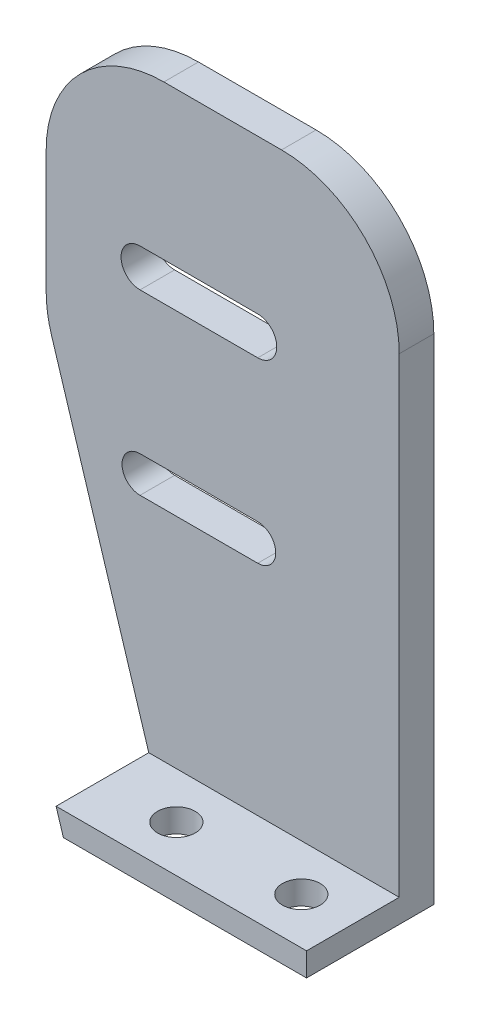
from build123d import *

# Parameters (mm, degrees)
SKETCH1_W                      = 30
SKETCH1_H                      = 10.814576134
BOSS_EXTRUDE1_DEPTH            = 2
SKETCH2_W                      = 30
SKETCH2_H                      = 2.938330184
BOSS_EXTRUDE2_DEPTH            = 50
CUT_EXTRUDE1_DEPTH             = 11.814576135
CUT_EXTRUDE2_REACH             = 4
SKETCH4_R                      = 1.6
CUT_EXTRUDE3_REACH             = 8.878
CUT_EXTRUDE3_DIRECTION_2_REACH = 5.937
FILLET1_R                      = 10


with BuildPart() as part:
    # Sketch1 → Boss-Extrude1 (new body)
    with BuildSketch(Plane(origin=(0, 0, 0), x_dir=(1, 0, 0), z_dir=(0, 1, 0))):
        with Locations((0, -1.470280193)):
            Rectangle(SKETCH1_W, SKETCH1_H)
    extrude(amount=BOSS_EXTRUDE1_DEPTH)

    # Sketch2 → Boss-Extrude2 (add)
    with BuildSketch(Plane(origin=(0, 2, 0), x_dir=(1, 0, 0), z_dir=(0, 1, 0))):
        with Locations((0, 2.467842782)):
            Rectangle(SKETCH2_W, SKETCH2_H)
    extrude(amount=BOSS_EXTRUDE2_DEPTH)

    # Sketch3 → Cut-Extrude1 (cut, through all)
    with BuildSketch(Plane(origin=(0, 0, -3.937007874), x_dir=(-1, 0, 0), z_dir=(0, 0, -1))):
        with BuildLine():
            Line((-2.975613291, 38.918099038), (7.024386709, 38.918099038))
            ThreePointArc((7.024386709, 38.918099038), (8.639544063, 37.302941685), (7.024386709, 35.687784331))
            Line((7.024386709, 35.687784331), (-2.975613291, 35.687784331))
            ThreePointArc((-2.975613291, 35.687784331), (-4.590770645, 37.302941685), (-2.975613291, 38.918099038))
        make_face()
        with BuildLine():
            Line((-2.975613291, 23.633431947), (7.024386709, 23.633431947))
            ThreePointArc((7.024386709, 23.633431947), (8.554876972, 22.102941685), (7.024386709, 20.572451422))
            Line((7.024386709, 20.572451422), (-2.975613291, 20.572451422))
            ThreePointArc((-2.975613291, 20.572451422), (-4.506103554, 22.102941685), (-2.975613291, 23.633431947))
        make_face()
    extrude(amount=-CUT_EXTRUDE1_DEPTH, mode=Mode.SUBTRACT)

    # Sketch4 → Cut-Extrude2 (cut, up to next)
    with BuildSketch(Plane(origin=(0, 2, 0), x_dir=(1, 0, 0), z_dir=(0, 1, 0)), mode=Mode.PRIVATE) as cut_extrude2_sk1:
        with Locations((10.61893739, -2.939445285)):
            Circle(SKETCH4_R)
    cut_extrude2_tool1 = extrude(cut_extrude2_sk1.sketch, amount=-CUT_EXTRUDE2_REACH, mode=Mode.PRIVATE) & part.part
    add(cut_extrude2_tool1.solids().sort_by_distance((10.618937, 2, 2.939445))[0], mode=Mode.SUBTRACT)
    # Sketch4 → Cut-Extrude2 (cut, up to next)
    with BuildSketch(Plane(origin=(0, 2, 0), x_dir=(1, 0, 0), z_dir=(0, 1, 0)), mode=Mode.PRIVATE) as cut_extrude2_sk2:
        with Locations((0, -2.939445285)):
            Circle(SKETCH4_R)
    cut_extrude2_tool2 = extrude(cut_extrude2_sk2.sketch, amount=-CUT_EXTRUDE2_REACH, mode=Mode.PRIVATE) & part.part
    add(cut_extrude2_tool2.solids().sort_by_distance((0, 2, 2.939445))[0], mode=Mode.SUBTRACT)

    # Sketch5 → Cut-Extrude3 (cut, up to next)
    with BuildSketch(Plane.XY, mode=Mode.PRIVATE) as cut_extrude3_sk1:
        Polygon((-4.080923029, -5.080850433), (-16.955695167, 36.332562893), (-18.585937562, -5.080850433), align=None)
    cut_extrude3_tool1 = extrude(cut_extrude3_sk1.sketch, amount=CUT_EXTRUDE3_REACH, mode=Mode.PRIVATE) & part.part
    add(cut_extrude3_tool1.solids().sort_by_distance((-13.207519, 8.723621, 0))[0], mode=Mode.SUBTRACT)

    # Sketch5 → Cut-Extrude3 direction 2 (cut, up to next)
    with BuildSketch(Plane.XY, mode=Mode.PRIVATE) as cut_extrude3_direction_2_sk1:
        Polygon((-4.080923029, -5.080850433), (-16.955695167, 36.332562893), (-18.585937562, -5.080850433), align=None)
    cut_extrude3_direction_2_tool1 = extrude(cut_extrude3_direction_2_sk1.sketch, amount=-CUT_EXTRUDE3_DIRECTION_2_REACH, mode=Mode.PRIVATE) & part.part
    add(cut_extrude3_direction_2_tool1.solids().sort_by_distance((-13.207519, 8.723621, 0))[0], mode=Mode.SUBTRACT)

    # Fillet1
    fillet1_edges = [part.edges().sort_by_distance(p)[0] for p in [
        (15, 52, -2.467842782),
        (-15, 52, -2.467842782),
        (-15, 30.041809827, -2.467842782),
    ]]
    fillet(fillet1_edges, radius=FILLET1_R)


solid = part.part
